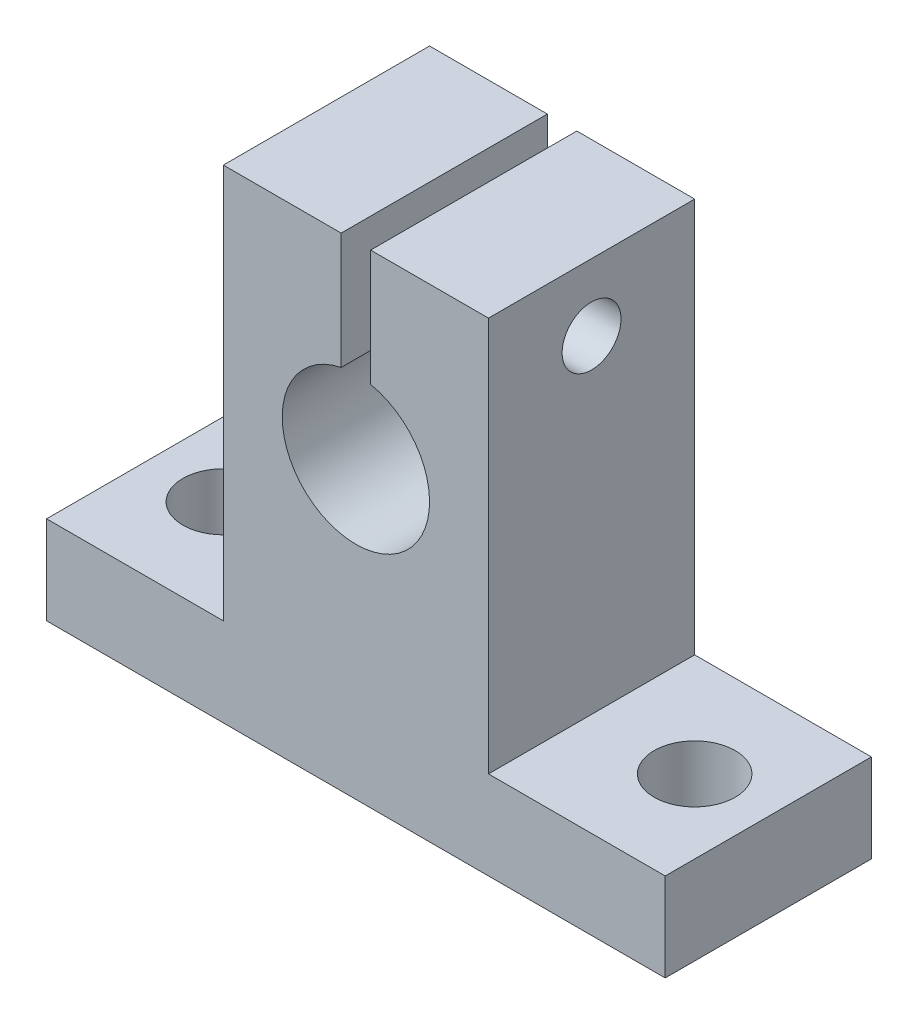
from build123d import *

# Parameters (mm, degrees)
BOSS_EXTRUDE1_DEPTH = 14
SKETCH2_R           = 2.75
CUT_EXTRUDE1_DEPTH  = 7
SKETCH3_R           = 2
CUT_EXTRUDE2_DEPTH  = 31
SKETCH4_R           = 3.5
CUT_EXTRUDE3_DEPTH  = 3


with BuildPart() as part:
    # Sketch1 → Boss-Extrude1 (new body)
    with BuildSketch(Plane.XY):
        with BuildLine():
            Line((0, 0), (42, 0))
            Line((42, 0), (42, 6))
            Line((42, 6), (30, 6))
            Line((30, 6), (30, 32.8))
            Line((30, 32.8), (22, 32.8))
            Line((22, 32.8), (22, 24.898979486))
            ThreePointArc((22, 24.898979486), (21, 15), (20, 24.898979486))
            Line((20, 24.898979486), (20, 32.8))
            Line((20, 32.8), (12, 32.8))
            Line((12, 32.8), (12, 6))
            Line((12, 6), (0, 6))
            Line((0, 6), (0, 0))
        make_face()
    extrude(amount=BOSS_EXTRUDE1_DEPTH)

    # Sketch2 → Cut-Extrude1 (cut, through all)
    with BuildSketch(Plane(origin=(0, 6, 0), x_dir=(1, 0, 0), z_dir=(0, 1, 0))):
        with Locations((5, -7)):
            Circle(SKETCH2_R)
        with Locations((37, -7)):
            Circle(SKETCH2_R)
    extrude(amount=-CUT_EXTRUDE1_DEPTH, mode=Mode.SUBTRACT)

    # Sketch3 → Cut-Extrude2 (cut, through all)
    with BuildSketch(Plane.ZY.offset(-12)):
        with Locations((7, 28.254234055)):
            Circle(SKETCH3_R)
    extrude(amount=-CUT_EXTRUDE2_DEPTH, mode=Mode.SUBTRACT)

    # Sketch4 → Cut-Extrude3 (cut)
    with BuildSketch(Plane.ZY.offset(-12)):
        with Locations((7, 28.254234055)):
            Circle(SKETCH4_R)
    extrude(amount=-CUT_EXTRUDE3_DEPTH, mode=Mode.SUBTRACT)


solid = part.part
